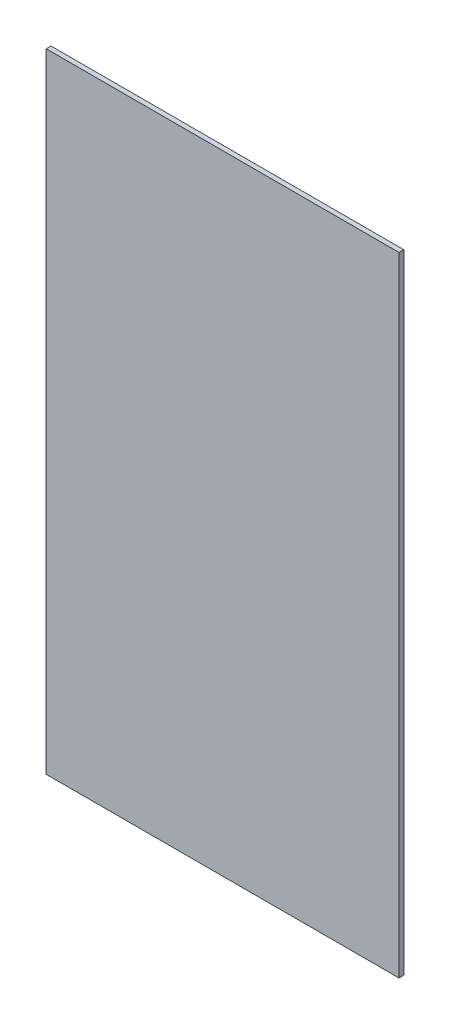
from build123d import *

# Parameters (mm, degrees)
SKETCH1_W                 = 112.268
SKETCH1_H                 = 200
BOTTOM_OUTER_CASING_DEPTH = 1.51892


with BuildPart() as part:
    # Sketch1 → Bottom Outer Casing (new body)
    with BuildSketch(Plane.XY):
        with Locations((56.134, 100)):
            Rectangle(SKETCH1_W, SKETCH1_H)
    extrude(amount=BOTTOM_OUTER_CASING_DEPTH)


solid = part.part
